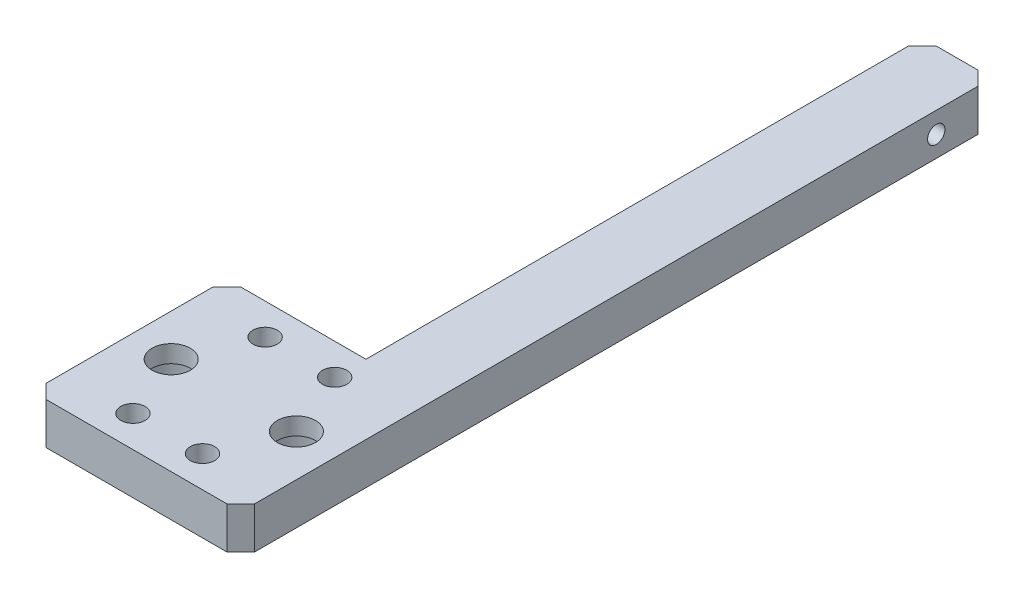
from build123d import *

# Parameters (mm, degrees)
SKETCH_1_W               = 30
SKETCH_1_H               = 28
EXTRUDE_1_DEPTH          = 6
SKETCH_2_R               = 1.75
CUT_EXTRUDE_1_DEPTH      = 22.377558326
CUT_EXTRUDE_4_DEPTH      = 3.5
CUT_EXTRUDE_4_DEPTH_BACK = 22.377558326
SKETCH_4_R               = 2.75
EXTRUDE_2_DEPTH          = 6
SKETCH_6_R               = 5
CUT_EXTRUDE_5_DEPTH      = 3.5
CHAMFER_1_SIZE           = 2
CUT_EXTRUDE_6_REACH      = 98.291
SKETCH_8_R               = 1.25


with BuildPart() as part:
    # 草图1 → 凸台-拉伸1 (new body)
    with BuildSketch(Plane(origin=(0, 0, 0), x_dir=(1, 0, 0), z_dir=(0, 1, 0))):
        Rectangle(SKETCH_1_W, SKETCH_1_H)
    extrude(amount=EXTRUDE_1_DEPTH)

    # 草图2 → 切除-拉伸1 (cut, through all)
    with BuildSketch(Plane(origin=(0, 6, 0), x_dir=(1, 0, 0), z_dir=(0, 1, 0))):
        with Locations((-5, 9.5)):
            Circle(SKETCH_2_R)
        with Locations((5, 9.5)):
            Circle(SKETCH_2_R)
        with Locations((-5, -9.5)):
            Circle(SKETCH_2_R)
        with Locations((5, -9.5)):
            Circle(SKETCH_2_R)
    extrude(amount=-CUT_EXTRUDE_1_DEPTH, mode=Mode.SUBTRACT)

    # 草图4 → 切除-拉伸4 (cut, two sides: drawn at the far end of the back side and taken through both)
    with BuildSketch(Plane.XZ.offset(-CUT_EXTRUDE_4_DEPTH_BACK)):
        with Locations((-9, 0)):
            Circle(SKETCH_4_R)
        with Locations((9, 0)):
            Circle(SKETCH_4_R)
    extrude(amount=CUT_EXTRUDE_4_DEPTH + CUT_EXTRUDE_4_DEPTH_BACK, mode=Mode.SUBTRACT)

    # 草图7 → 凸台-拉伸2 (add)
    with BuildSketch(Plane(origin=(0, 6, 0), x_dir=(1, 0, 0), z_dir=(0, 1, 0))):
        Polygon((15, 74), (15, 14), (5, 14), (5, 64), (5, 94), (15, 94), align=None)
    extrude(amount=-EXTRUDE_2_DEPTH)

    # 草图6 → 切除-拉伸5 (cut)
    with BuildSketch(Plane.XZ):
        with Locations((-9, 0)):
            Circle(SKETCH_6_R)
        with Locations((9, 0)):
            Circle(SKETCH_6_R)
    extrude(amount=-CUT_EXTRUDE_5_DEPTH, mode=Mode.SUBTRACT)

    # 倒角1
    chamfer_1_edges = [part.edges().sort_by_distance(p)[0] for p in [
        (15, 3, 14),
        (-15, 3, 14),
        (5, 3, -94),
        (15, 3, -94),
        (-15, 3, -14),
    ]]
    chamfer(chamfer_1_edges, length=CHAMFER_1_SIZE)

    # 草图8 → 切除-拉伸6 (cut, up to next)
    with BuildSketch(Plane.ZY.offset(-5), mode=Mode.PRIVATE) as cut_extrude_6_sk1:
        with Locations((-86, 3)):
            Circle(SKETCH_8_R)
    cut_extrude_6_tool1 = extrude(cut_extrude_6_sk1.sketch, amount=-CUT_EXTRUDE_6_REACH, mode=Mode.PRIVATE) & part.part
    add(cut_extrude_6_tool1.solids().sort_by_distance((5, 3, -86))[0], mode=Mode.SUBTRACT)


solid = part.part
